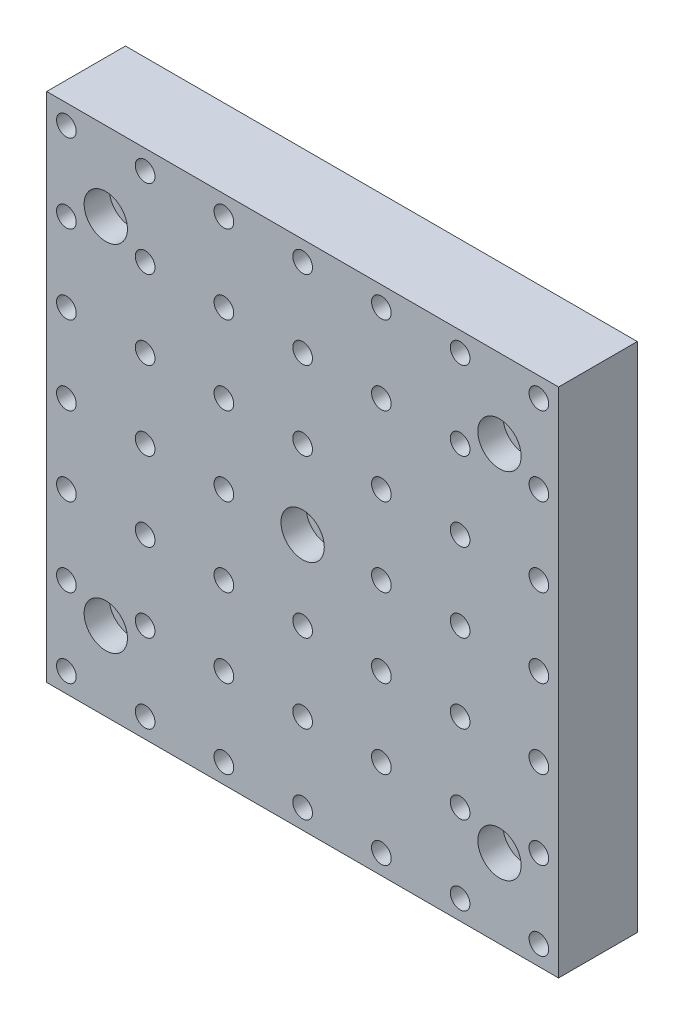
from build123d import *

# Parameters (mm, degrees)
SKETCH1_W                                           = 130
SKETCH1_H                                           = 130
EXTRUDE1_DEPTH                                      = 20
M6_TAPPED_HOLE1_D                                   = 5
CBORE_FOR_M6_HEX_SOCKET_HEAD_CAP_SCREW1_D           = 6.6
CBORE_FOR_M6_HEX_SOCKET_HEAD_CAP_SCREW1_CBORE_D     = 11
CBORE_FOR_M6_HEX_SOCKET_HEAD_CAP_SCREW1_CBORE_DEPTH = 6.4


with BuildPart() as part:
    # Sketch1 → Extrude1 (new body)
    with BuildSketch(Plane.XY):
        Rectangle(SKETCH1_W, SKETCH1_H)
    extrude(amount=EXTRUDE1_DEPTH)

    # M6 Tapped Hole1 (through all)
    with Locations(Plane.XY.offset(20)):
        with Locations((-60, -60), (-40, -60), (-20, -60), (0, -60), (20, -60), (40, -60), (-40, -40), (-20, -40), (0, -40), (20, -40), (40, -40), (-40, -20), (-20, -20), (0, -20), (20, -20), (40, -20), (-40, 0), (-20, 0), (0, 0), (20, 0), (40, 0), (-40, 20), (-20, 20), (0, 20), (20, 20), (40, 20), (-40, 40), (-20, 40), (0, 40), (20, 40), (40, 40), (-40, 60), (-20, 60), (0, 60), (20, 60), (40, 60), (-60, -40), (-60, -20), (-60, 0), (-60, 20), (-60, 40), (-60, 60), (60, -60), (60, -40), (60, -20), (60, 0), (60, 20), (60, 40), (60, 60)):
            Hole(M6_TAPPED_HOLE1_D / 2)

    # CBORE for M6 Hex Socket Head Cap Screw1 (through all)
    with Locations(Plane.XY.offset(20)):
        with Locations((-50, 45), (50, 45), (50, -45), (-50, -45), (0, 0)):
            CounterBoreHole(CBORE_FOR_M6_HEX_SOCKET_HEAD_CAP_SCREW1_D / 2, CBORE_FOR_M6_HEX_SOCKET_HEAD_CAP_SCREW1_CBORE_D / 2, CBORE_FOR_M6_HEX_SOCKET_HEAD_CAP_SCREW1_CBORE_DEPTH)


solid = part.part
